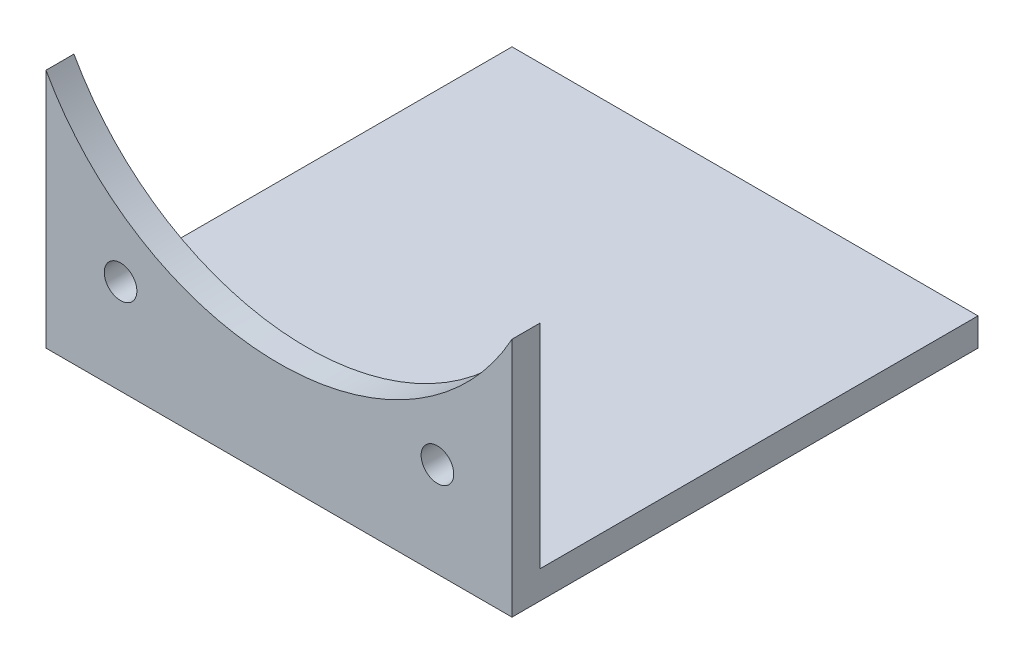
from build123d import *

# Parameters (mm, degrees)
SKETCH_1_W          = 47
SKETCH_1_H          = 3
EXTRUDE_1_DEPTH     = 25
SKETCH_2_R          = 1.75
SKETCH_2_R_2        = 28.55
CUT_EXTRUDE_1_DEPTH = 4


with BuildPart() as part:
    # 草圖1 → 填料-伸長1 (new body, symmetric)
    with BuildSketch(Plane(origin=(0, 0, 0), x_dir=(0, 0, -1), z_dir=(1, 0, 0))):
        Polygon((0, 50), (0, 0), (3, 0), (3, 3), (3, 50), align=None)
        with Locations((26.5, 1.5)):
            Rectangle(SKETCH_1_W, SKETCH_1_H)
    extrude(amount=EXTRUDE_1_DEPTH, both=True)

    # 草圖2 → 除料-伸長1 (cut, through all)
    with BuildSketch(Plane(origin=(0, 0, -3), x_dir=(-1, 0, 0), z_dir=(0, 0, -1))):
        with Locations((17, 10.172548614)):
            Circle(SKETCH_2_R)
        with Locations((-17, 10.172548614)):
            Circle(SKETCH_2_R)
        with Locations((-34, 39.617412342)):
            Circle(SKETCH_2_R)
        with Locations((-17, 69.062276071)):
            Circle(SKETCH_2_R)
        with Locations((17, 69.062276071)):
            Circle(SKETCH_2_R)
        with Locations((34, 39.617412342)):
            Circle(SKETCH_2_R)
        with Locations((0, 39.617412342)):
            Circle(SKETCH_2_R_2)
    extrude(amount=-CUT_EXTRUDE_1_DEPTH, mode=Mode.SUBTRACT)


solid = part.part
